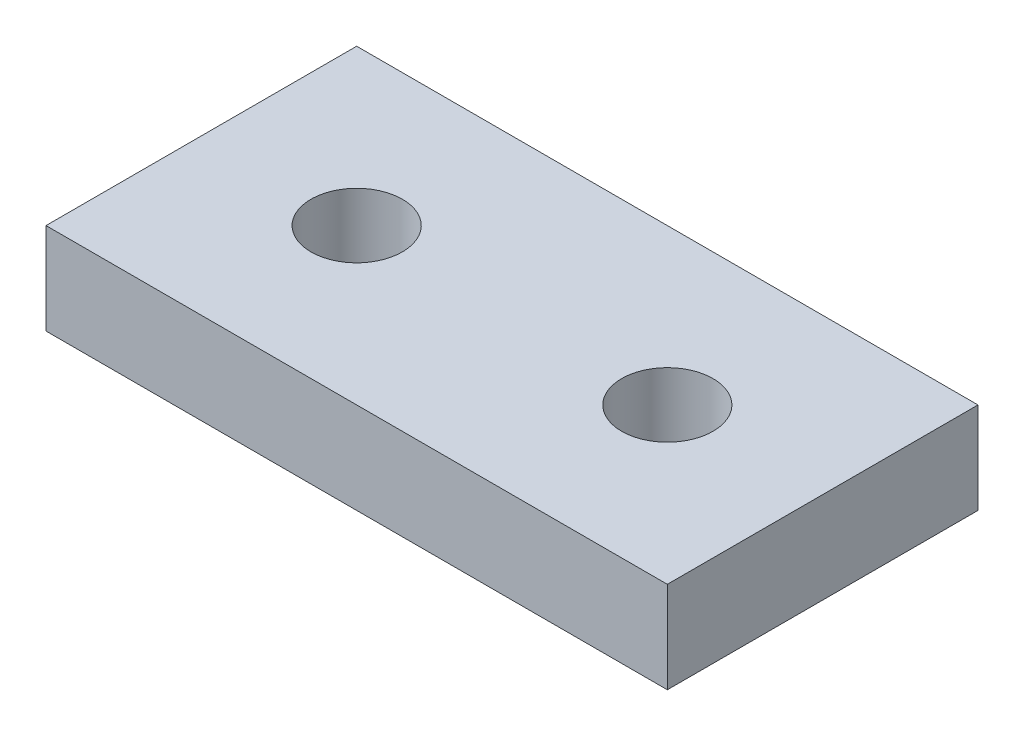
from build123d import *

# Parameters (mm, degrees)
SKETCH1_W           = 34
SKETCH1_H           = 17
SKETCH1_R           = 2.5
BOSS_EXTRUDE1_DEPTH = 5


with BuildPart() as part:
    # sketch1 → Boss-Extrude1 (new body)
    with BuildSketch(Plane(origin=(0, 0, 0), x_dir=(1, 0, 0), z_dir=(0, 1, 0))):
        with Locations((17, -8.5)):
            Rectangle(SKETCH1_W, SKETCH1_H)
        with Locations((8.5, -8.5)):
            Circle(SKETCH1_R, mode=Mode.SUBTRACT)
        with Locations((25.5, -8.5)):
            Circle(SKETCH1_R, mode=Mode.SUBTRACT)
    extrude(amount=BOSS_EXTRUDE1_DEPTH)


solid = part.part
